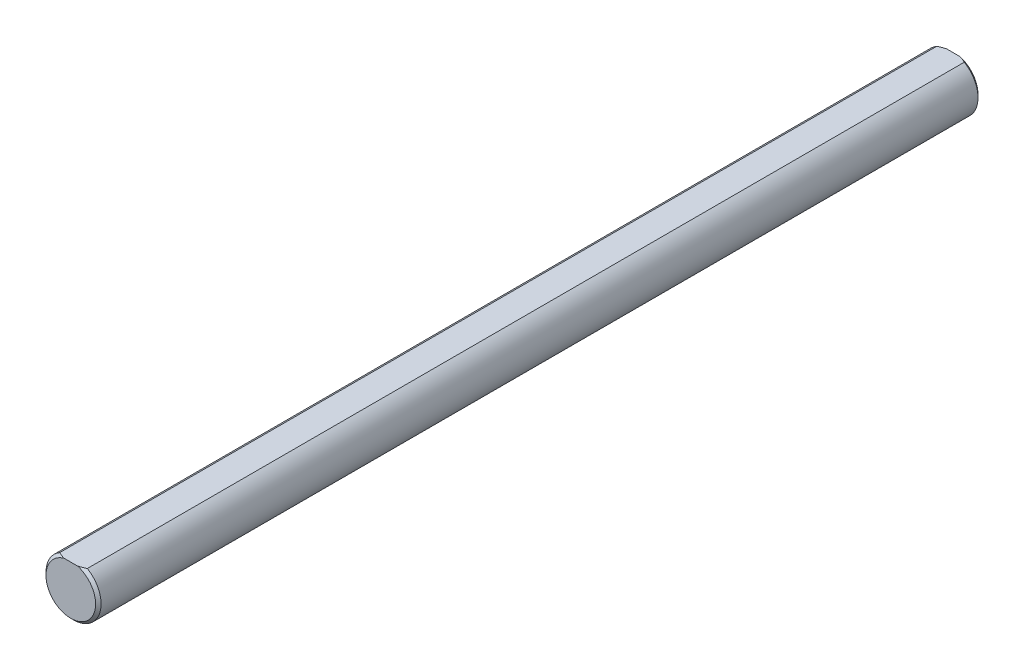
from build123d import *

# Parameters (mm, degrees)
SKETCH3_R                = 4.7625
BOSS_EXTRUDE2_DEPTH      = 76.2
BOSS_EXTRUDE2_DEPTH_BACK = 76.2
CUT_EXTRUDE5_DEPTH       = 77.2
CUT_EXTRUDE5_DEPTH_BACK  = 77.2
CHAMFER1_SIZE            = 0.47625


with BuildPart() as part:
    # Sketch3 → Boss-Extrude2 (new body, two sides)
    with BuildSketch(Plane.XY) as boss_extrude2_sk:
        Circle(SKETCH3_R)
    extrude(amount=BOSS_EXTRUDE2_DEPTH)
    extrude(boss_extrude2_sk.sketch, amount=-BOSS_EXTRUDE2_DEPTH_BACK)

    # Sketch10 → Cut-Extrude5 (cut, two sides)
    with BuildSketch(Plane.XY) as cut_extrude5_sk:
        with BuildLine():
            Line((-2.38125, 4.124445986), (2.38125, 4.124445986))
            ThreePointArc((2.38125, 4.124445986), (0, 4.7625), (-2.38125, 4.124445986))
        make_face()
    extrude(amount=CUT_EXTRUDE5_DEPTH, mode=Mode.SUBTRACT)
    extrude(cut_extrude5_sk.sketch, amount=-CUT_EXTRUDE5_DEPTH_BACK, mode=Mode.SUBTRACT)

    # Chamfer1
    chamfer1_edges = [part.edges().sort_by_distance(p)[0] for p in [
        (0, -4.7625, -76.2),
        (0, -4.7625, 76.2),
    ]]
    chamfer(chamfer1_edges, length=CHAMFER1_SIZE)


solid = part.part
